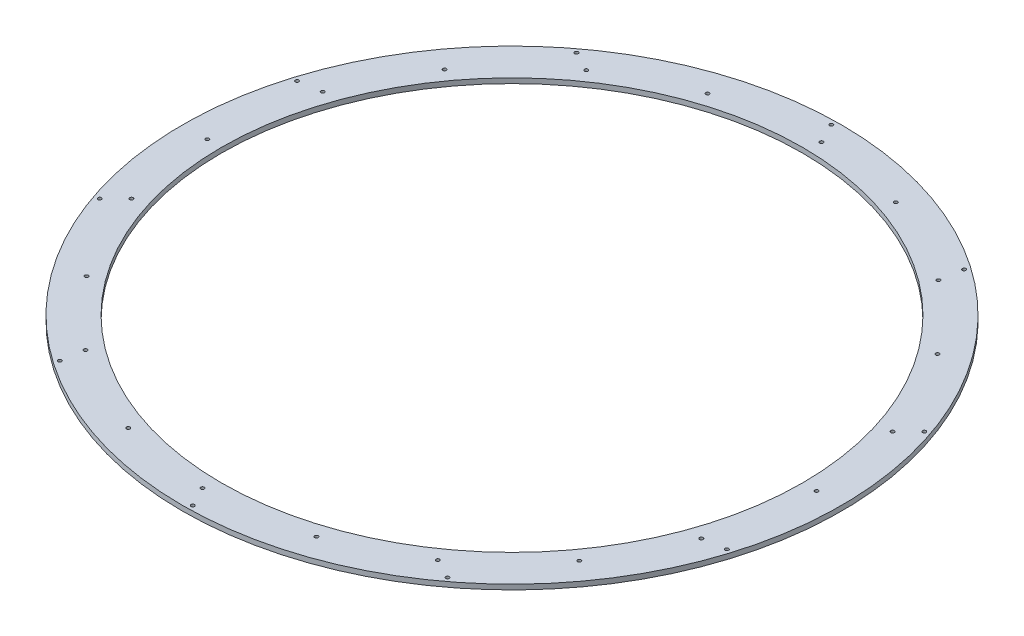
from build123d import *

# Parameters (mm, degrees)
SKETCH1_R           = 330
SKETCH1_R_2         = 291
BOSS_EXTRUDE1_DEPTH = 5
SKETCH2_R           = 1.75
CUT_EXTRUDE1_DEPTH  = 6
CIRPATTERN1_COUNT   = 10


with BuildPart() as part:
    # Sketch1 → Boss-Extrude1 (new body)
    with BuildSketch(Plane(origin=(0, 0, 0), x_dir=(1, 0, 0), z_dir=(0, 1, 0))):
        Circle(SKETCH1_R)
        Circle(SKETCH1_R_2, mode=Mode.SUBTRACT)
    extrude(amount=-BOSS_EXTRUDE1_DEPTH)

    # Sketch2 → Cut-Extrude1 (cut, through all)
    with BuildSketch(Plane(origin=(0, 0, 0), x_dir=(1, 0, 0), z_dir=(0, 1, 0))):
        with Locations((5.238528177, -324.957778523)):
            Circle(SKETCH2_R)
        with Locations((94.250183284, -290.07223747)):
            Circle(SKETCH2_R)
        with Locations((175.273957266, -249.607772124)):
            Circle(SKETCH2_R)
    cut_extrude1 = extrude(amount=-CUT_EXTRUDE1_DEPTH, mode=Mode.SUBTRACT)

    # CirPattern1: Cut-Extrude1 ×10 about axis
    cirpattern1_axis = Axis((0, 0, 0), (0, 1, 0))
    for i in range(1, CIRPATTERN1_COUNT):
        add(cut_extrude1.rotate(cirpattern1_axis, i * 360 / CIRPATTERN1_COUNT), mode=Mode.SUBTRACT)


solid = part.part
